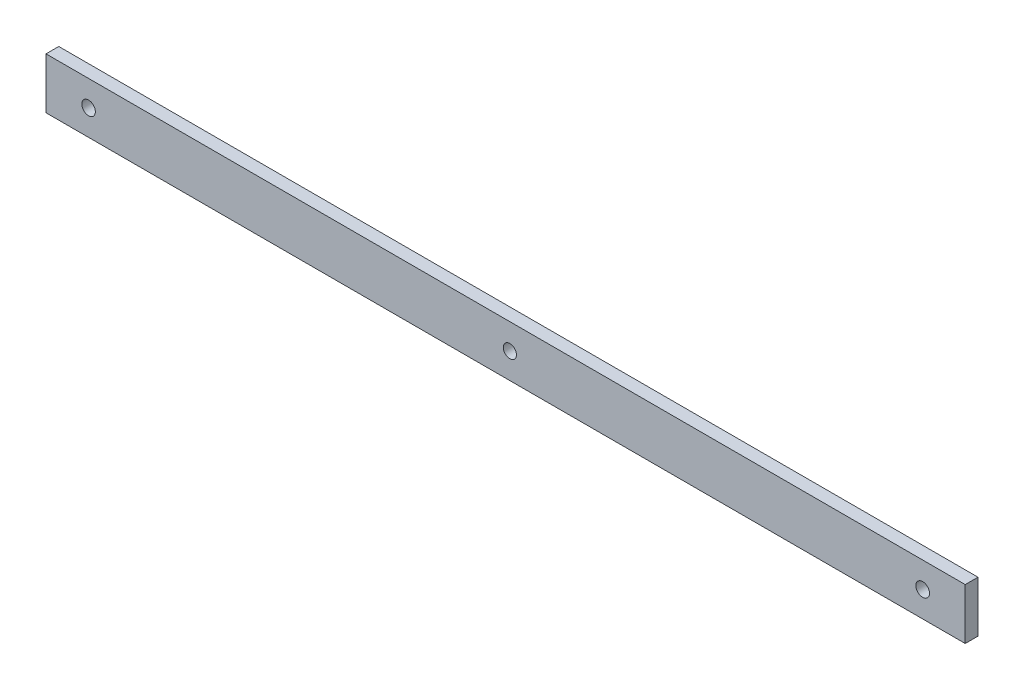
from build123d import *

# Parameters (mm, degrees)
SKETCH2_W           = 216
SKETCH2_H           = 12
SKETCH2_R           = 1.6
BOSS_EXTRUDE1_DEPTH = 3
SKETCH4_R           = 1.55
SKETCH4_R_2         = 1.6
CUT_EXTRUDE1_DEPTH  = 4


with BuildPart() as part:
    # Sketch2 → Boss-Extrude1 (new body)
    with BuildSketch(Plane.XY):
        with Locations((108, 6)):
            Rectangle(SKETCH2_W, SKETCH2_H)
        with Locations((206, 6)):
            Circle(SKETCH2_R, mode=Mode.SUBTRACT)
    extrude(amount=BOSS_EXTRUDE1_DEPTH)

    # Sketch4 → Cut-Extrude1 (cut, through all)
    with BuildSketch(Plane(origin=(0, 0, 0), x_dir=(-1, 0, 0), z_dir=(0, 0, -1))):
        with Locations((-109, 6)):
            Circle(SKETCH4_R)
        with Locations((-10, 6)):
            Circle(SKETCH4_R_2)
    extrude(amount=-CUT_EXTRUDE1_DEPTH, mode=Mode.SUBTRACT)


solid = part.part
